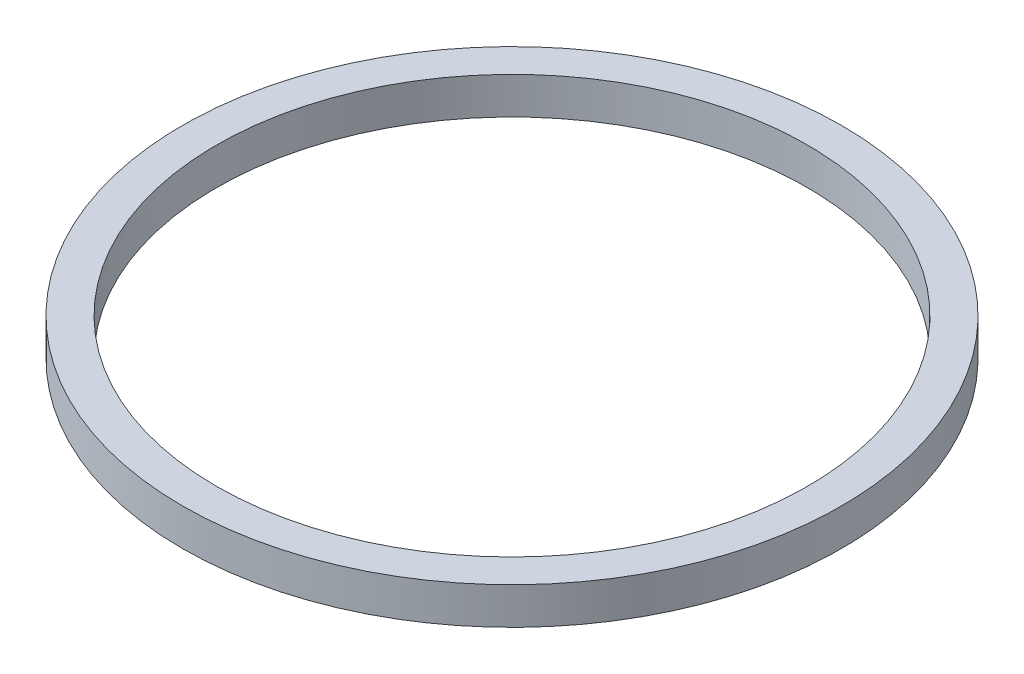
from build123d import *

# Parameters (mm, degrees)
SKETCH1_R           = 14.1605
SKETCH1_R_2         = 12.7
BOSS_EXTRUDE1_DEPTH = 1.5875


with BuildPart() as part:
    # Sketch1 → Boss-Extrude1 (new body)
    with BuildSketch(Plane(origin=(0, 0, 0), x_dir=(1, 0, 0), z_dir=(0, 1, 0))):
        Circle(SKETCH1_R)
        Circle(SKETCH1_R_2, mode=Mode.SUBTRACT)
    extrude(amount=BOSS_EXTRUDE1_DEPTH)


solid = part.part
